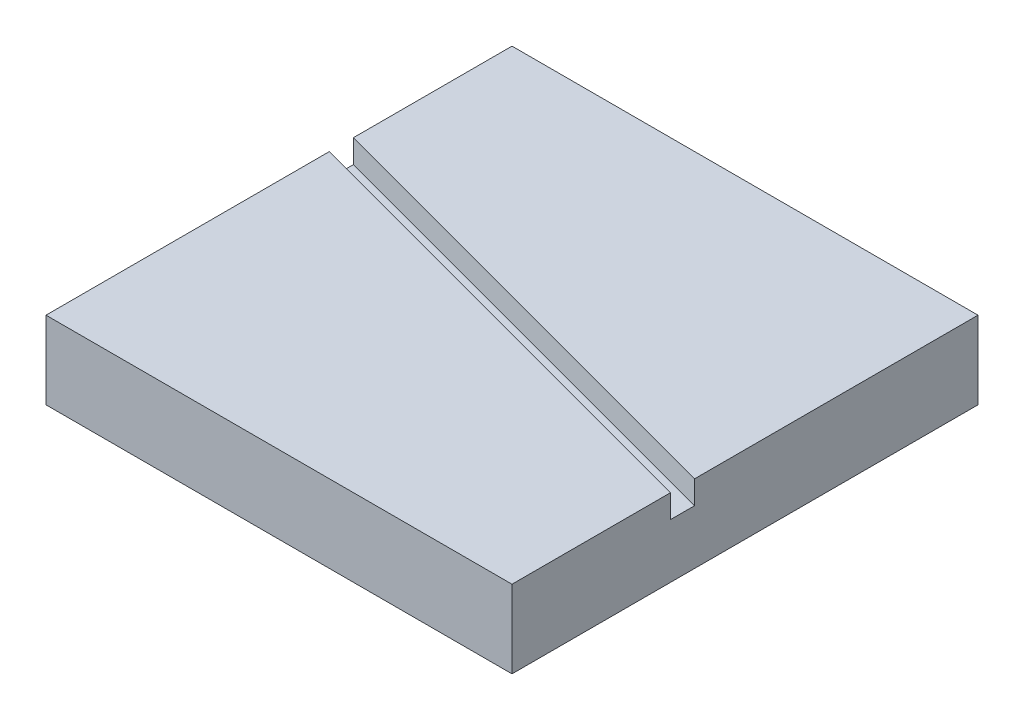
from build123d import *

# Parameters (mm, degrees)
SKETCH1_W           = 60
SKETCH1_H           = 60
BOSS_EXTRUDE1_DEPTH = 10
CUT_EXTRUDE1_DEPTH  = 3


with BuildPart() as part:
    # Sketch1 → Boss-Extrude1 (new body)
    with BuildSketch(Plane(origin=(0, 0, 0), x_dir=(1, 0, 0), z_dir=(0, 1, 0))):
        Rectangle(SKETCH1_W, SKETCH1_H)
    extrude(amount=BOSS_EXTRUDE1_DEPTH)

    # Sketch2 → Cut-Extrude1 (cut)
    with BuildSketch(Plane(origin=(0, 10, 0), x_dir=(1, 0, 0), z_dir=(0, 1, 0))):
        Polygon((-34.982332013, 7.820573342), (49.768078516, -14.888230718), (50.544535652, -11.990453239), (-34.205874878, 10.718350821), align=None)
    extrude(amount=-CUT_EXTRUDE1_DEPTH, mode=Mode.SUBTRACT)


solid = part.part
